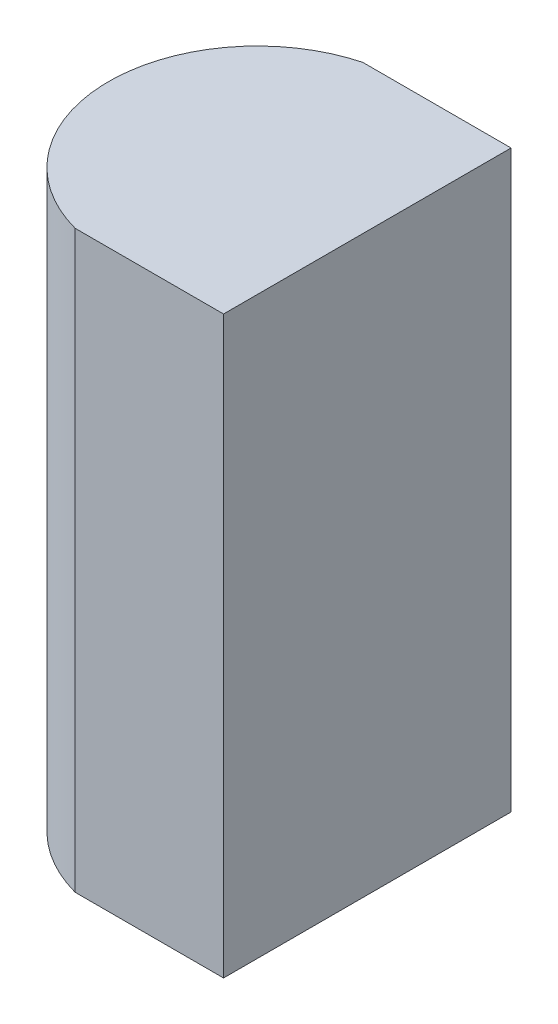
from build123d import *

# Parameters (mm, degrees)
EXTRUDE_1_DEPTH = 8


with BuildPart() as part:
    # 草图1 → 凸台-拉伸1 (new body)
    with BuildSketch(Plane(origin=(0, 0, 0), x_dir=(1, 0, 0), z_dir=(0, 1, 0))):
        with BuildLine():
            Line((0, 0), (0, -4))
            Line((0, -4), (-2.063760246, -4))
            ThreePointArc((-2.063760246, -4), (-3.6, -2), (-2.063760246, 0))
            Line((-2.063760246, 0), (0, 0))
        make_face()
    extrude(amount=EXTRUDE_1_DEPTH)


solid = part.part
